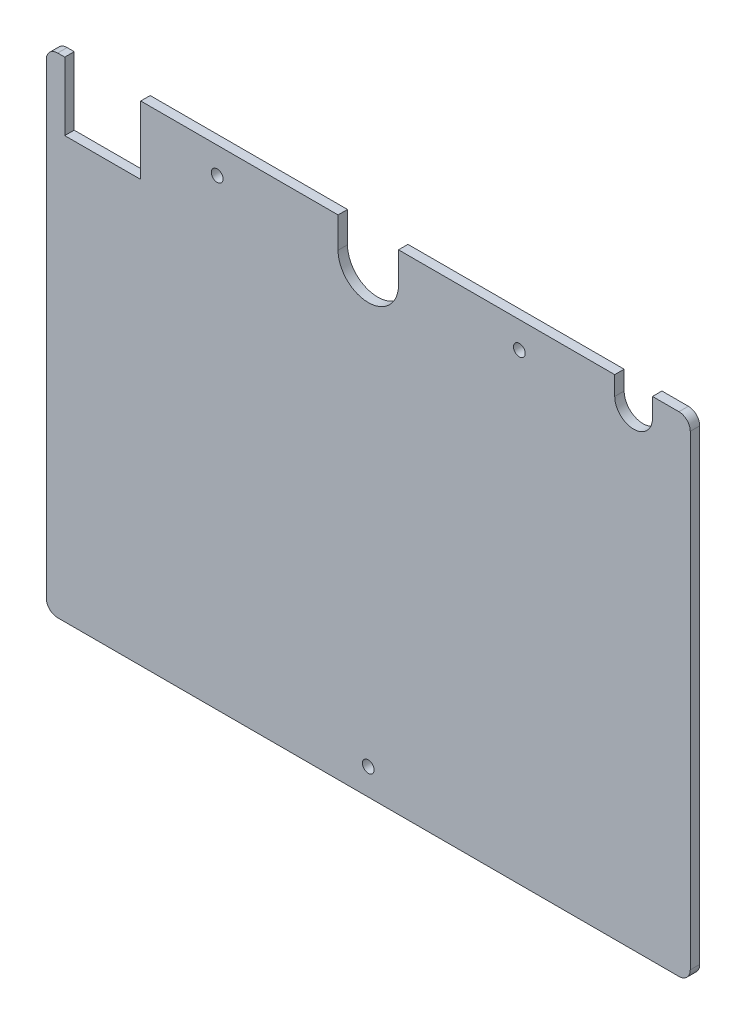
from build123d import *

# Parameters (mm, degrees)
RESSALTO_EXTRUS_O1_DEPTH = 2.5
ESBO_O2_R                = 1.55
ESBO_O2_W                = 20.114167529
ESBO_O2_H                = 18
CORTE_EXTRUS_O1_DEPTH    = 3.5


with BuildPart() as part:
    # Esboço1 → Ressalto-extrusão1 (new body)
    with BuildSketch(Plane.XY):
        with BuildLine():
            Line((-82.25, 64.75), (82.25, 64.75))
            ThreePointArc((82.25, 64.75), (84.371320344, 63.871320344), (85.25, 61.75))
            Line((85.25, 61.75), (85.25, -61.75))
            ThreePointArc((85.25, -61.75), (84.371320344, -63.871320344), (82.25, -64.75))
            Line((82.25, -64.75), (-82.25, -64.75))
            ThreePointArc((-82.25, -64.75), (-84.371320344, -63.871320344), (-85.25, -61.75))
            Line((-85.25, -61.75), (-85.25, 61.75))
            ThreePointArc((-85.25, 61.75), (-84.371320344, 63.871320344), (-82.25, 64.75))
        make_face()
    extrude(amount=RESSALTO_EXTRUS_O1_DEPTH)

    # Esboço2 → Corte-extrusão1 (cut, through all)
    with BuildSketch(Plane.XY.offset(2.5)):
        with Locations((0, -57.75)):
            Circle(ESBO_O2_R)
        with Locations((-40, 57.75)):
            Circle(ESBO_O2_R)
        with Locations((40, 57.75)):
            Circle(ESBO_O2_R)
        with BuildLine():
            Line((8, 56.65), (8, 64.75))
            Line((8, 64.75), (-8, 64.75))
            Line((-8, 64.75), (-8, 56.65))
            ThreePointArc((-8, 56.65), (0, 48.65), (8, 56.65))
        make_face()
        with Locations((-70.307083765, 55.75)):
            Rectangle(ESBO_O2_W, ESBO_O2_H)
        with BuildLine():
            Line((65.25, 64.75), (75.25, 64.75))
            Line((75.25, 64.75), (75.25, 59.75))
            ThreePointArc((75.25, 59.75), (70.25, 54.75), (65.25, 59.75))
            Line((65.25, 59.75), (65.25, 64.75))
        make_face()
    extrude(amount=-CORTE_EXTRUS_O1_DEPTH, mode=Mode.SUBTRACT)


solid = part.part
